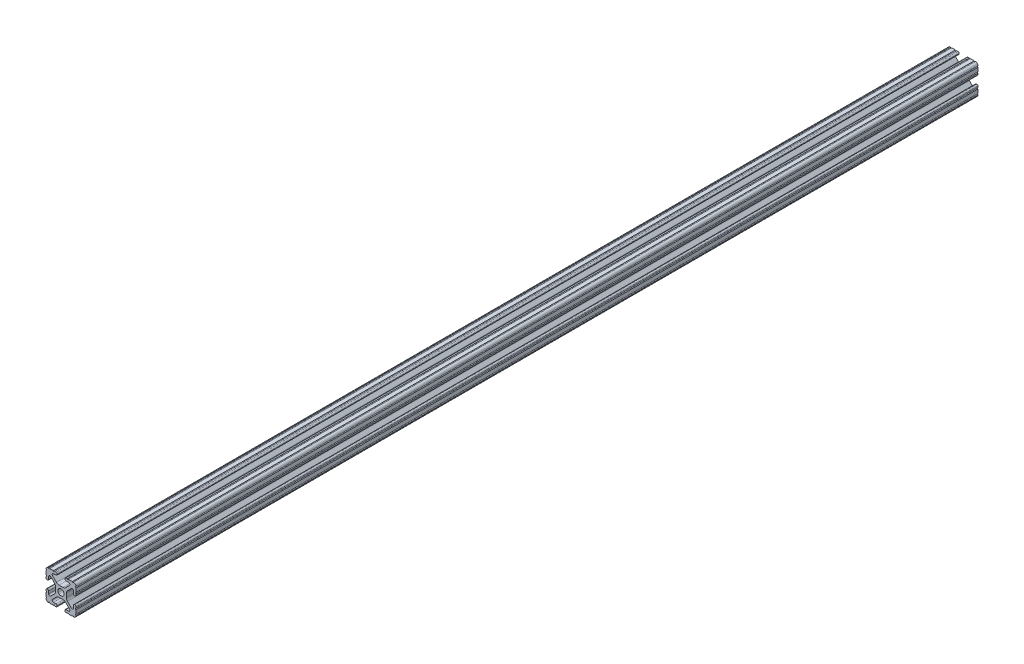
from build123d import *

# Parameters (mm, degrees)
SKETCH1_R           = 2.6035
BOSS_EXTRUDE1_DEPTH = 381


with BuildPart() as part:
    # Sketch1 → Boss-Extrude1 (new body, symmetric)
    with BuildSketch(Plane.XY):
        with BuildLine():
            Line((-7.179650497, -8.645192506), (-3.952270251, -5.423690499))
            ThreePointArc((-3.952270251, -5.423690499), (-2.922936451, -4.736929036), (-1.709253557, -4.4958))
            Line((-1.709253557, -4.4958), (1.709253557, -4.4958))
            ThreePointArc((1.709253557, -4.4958), (2.922936451, -4.736929036), (3.952270251, -5.423690499))
            Line((3.952270251, -5.423690499), (7.179650497, -8.645192506))
            ThreePointArc((7.179650497, -8.645192506), (7.41473083, -9.822813117), (6.416408329, -10.4902))
            Line((6.416408329, -10.4902), (4.287512407, -10.4902))
            ThreePointArc((4.287512407, -10.4902), (3.54574862, -10.79744862), (3.2385, -11.539212407))
            Line((3.2385, -11.539212407), (3.2385, -11.650987593))
            ThreePointArc((3.2385, -11.650987593), (3.54574862, -12.39275138), (4.287512407, -12.7))
            Line((4.287512407, -12.7), (5.317126718, -12.7))
            ThreePointArc((5.317126718, -12.7), (5.825126718, -12.192), (6.333126718, -12.7))
            Line((6.333126718, -12.7), (9.550443118, -12.7))
            ThreePointArc((9.550443118, -12.7), (10.058366869, -12.192000006), (10.566443095, -12.699847501))
            ThreePointArc((10.566443095, -12.699847501), (12.082537762, -12.08250727), (12.699846982, -10.566399977))
            ThreePointArc((12.699846982, -10.566399977), (12.192000006, -10.058323491), (12.7, -9.5504))
            Line((12.7, -9.5504), (12.7, -6.3330836))
            ThreePointArc((12.7, -6.3330836), (12.192, -5.8250836), (12.7, -5.3170836))
            Line((12.7, -5.3170836), (12.7, -4.287469289))
            ThreePointArc((12.7, -4.287469289), (12.39275138, -3.545705502), (11.650987593, -3.238456882))
            Line((11.650987593, -3.238456882), (11.539212407, -3.238456882))
            ThreePointArc((11.539212407, -3.238456882), (10.79744862, -3.545705502), (10.4902, -4.287469289))
            Line((10.4902, -4.287469289), (10.4902, -6.402089023))
            ThreePointArc((10.4902, -6.402089023), (9.856505071, -7.351067942), (8.737131347, -7.129408934))
            Line((8.737131347, -7.129408934), (5.441005833, -3.840816462))
            ThreePointArc((5.441005833, -3.840816462), (4.750877967, -2.809883091), (4.5085, -1.593185507))
            Line((4.5085, -1.593185507), (4.5085, 1.593185507))
            ThreePointArc((4.5085, 1.593185507), (4.750877967, 2.809883091), (5.441005833, 3.840816462))
            Line((5.441005833, 3.840816462), (8.737131347, 7.129408934))
            ThreePointArc((8.737131347, 7.129408934), (9.856505071, 7.351067942), (10.4902, 6.402089023))
            Line((10.4902, 6.402089023), (10.4902, 4.287469289))
            ThreePointArc((10.4902, 4.287469289), (10.79744862, 3.545705502), (11.539212407, 3.238456882))
            Line((11.539212407, 3.238456882), (11.650987593, 3.238456882))
            ThreePointArc((11.650987593, 3.238456882), (12.39275138, 3.545705502), (12.7, 4.287469289))
            Line((12.7, 4.287469289), (12.7, 5.3170836))
            ThreePointArc((12.7, 5.3170836), (12.192, 5.8250836), (12.7, 6.3330836))
            Line((12.7, 6.3330836), (12.7, 9.5504))
            ThreePointArc((12.7, 9.5504), (12.192000006, 10.058323491), (12.699846982, 10.566399977))
            ThreePointArc((12.699846982, 10.566399977), (12.082537762, 12.08250727), (10.566443095, 12.699847501))
            ThreePointArc((10.566443095, 12.699847501), (10.058366869, 12.192000006), (9.550443118, 12.7))
            Line((9.550443118, 12.7), (6.333126718, 12.7))
            ThreePointArc((6.333126718, 12.7), (5.825126718, 12.192), (5.317126718, 12.7))
            Line((5.317126718, 12.7), (4.287512407, 12.7))
            ThreePointArc((4.287512407, 12.7), (3.54574862, 12.39275138), (3.2385, 11.650987593))
            Line((3.2385, 11.650987593), (3.2385, 11.539212407))
            ThreePointArc((3.2385, 11.539212407), (3.54574862, 10.79744862), (4.287512407, 10.4902))
            Line((4.287512407, 10.4902), (6.476788598, 10.4902))
            ThreePointArc((6.476788598, 10.4902), (7.432222385, 9.85140422), (7.207036008, 8.724370562))
            Line((7.207036008, 8.724370562), (3.898272566, 5.423169045))
            ThreePointArc((3.898272566, 5.423169045), (2.869120213, 4.736787962), (1.655778399, 4.4958))
            Line((1.655778399, 4.4958), (-1.655778399, 4.4958))
            ThreePointArc((-1.655778399, 4.4958), (-2.869120213, 4.736787962), (-3.898272566, 5.423169045))
            Line((-3.898272566, 5.423169045), (-7.207036008, 8.724370562))
            ThreePointArc((-7.207036008, 8.724370562), (-7.432222385, 9.85140422), (-6.476788598, 10.4902))
            Line((-6.476788598, 10.4902), (-4.287512407, 10.4902))
            ThreePointArc((-4.287512407, 10.4902), (-3.54574862, 10.79744862), (-3.2385, 11.539212407))
            Line((-3.2385, 11.539212407), (-3.2385, 11.650987593))
            ThreePointArc((-3.2385, 11.650987593), (-3.54574862, 12.39275138), (-4.287512407, 12.7))
            Line((-4.287512407, 12.7), (-5.317126718, 12.7))
            ThreePointArc((-5.317126718, 12.7), (-5.825126718, 12.192), (-6.333126718, 12.7))
            Line((-6.333126718, 12.7), (-9.550443118, 12.7))
            ThreePointArc((-9.550443118, 12.7), (-10.058366869, 12.192000006), (-10.566443095, 12.699847501))
            ThreePointArc((-10.566443095, 12.699847501), (-12.082537762, 12.08250727), (-12.699846982, 10.566399977))
            ThreePointArc((-12.699846982, 10.566399977), (-12.192000006, 10.058323491), (-12.7, 9.5504))
            Line((-12.7, 9.5504), (-12.7, 6.3330836))
            ThreePointArc((-12.7, 6.3330836), (-12.192, 5.8250836), (-12.7, 5.3170836))
            Line((-12.7, 5.3170836), (-12.7, 4.287469289))
            ThreePointArc((-12.7, 4.287469289), (-12.39275138, 3.545705502), (-11.650987593, 3.238456882))
            Line((-11.650987593, 3.238456882), (-11.539212407, 3.238456882))
            ThreePointArc((-11.539212407, 3.238456882), (-10.79744862, 3.545705502), (-10.4902, 4.287469289))
            Line((-10.4902, 4.287469289), (-10.4902, 6.402089023))
            ThreePointArc((-10.4902, 6.402089023), (-9.856505071, 7.351067942), (-8.737131347, 7.129408934))
            Line((-8.737131347, 7.129408934), (-5.441005833, 3.840816462))
            ThreePointArc((-5.441005833, 3.840816462), (-4.750877967, 2.809883091), (-4.5085, 1.593185507))
            Line((-4.5085, 1.593185507), (-4.5085, -1.593185507))
            ThreePointArc((-4.5085, -1.593185507), (-4.750877967, -2.809883091), (-5.441005833, -3.840816462))
            Line((-5.441005833, -3.840816462), (-8.737131347, -7.129408934))
            ThreePointArc((-8.737131347, -7.129408934), (-9.856505071, -7.351067942), (-10.4902, -6.402089023))
            Line((-10.4902, -6.402089023), (-10.4902, -4.287469289))
            ThreePointArc((-10.4902, -4.287469289), (-10.79744862, -3.545705502), (-11.539212407, -3.238456882))
            Line((-11.539212407, -3.238456882), (-11.650987593, -3.238456882))
            ThreePointArc((-11.650987593, -3.238456882), (-12.39275138, -3.545705502), (-12.7, -4.287469289))
            Line((-12.7, -4.287469289), (-12.7, -5.3170836))
            ThreePointArc((-12.7, -5.3170836), (-12.192, -5.8250836), (-12.7, -6.3330836))
            Line((-12.7, -6.3330836), (-12.7, -9.5504))
            ThreePointArc((-12.7, -9.5504), (-12.192000006, -10.058323491), (-12.699846982, -10.566399977))
            ThreePointArc((-12.699846982, -10.566399977), (-12.082537762, -12.08250727), (-10.566443095, -12.699847501))
            ThreePointArc((-10.566443095, -12.699847501), (-10.058366869, -12.192000006), (-9.550443118, -12.7))
            Line((-9.550443118, -12.7), (-6.333126718, -12.7))
            ThreePointArc((-6.333126718, -12.7), (-5.825126718, -12.192), (-5.317126718, -12.7))
            Line((-5.317126718, -12.7), (-4.287512407, -12.7))
            ThreePointArc((-4.287512407, -12.7), (-3.54574862, -12.39275138), (-3.2385, -11.650987593))
            Line((-3.2385, -11.650987593), (-3.2385, -11.539212407))
            ThreePointArc((-3.2385, -11.539212407), (-3.54574862, -10.79744862), (-4.287512407, -10.4902))
            Line((-4.287512407, -10.4902), (-6.416408329, -10.4902))
            ThreePointArc((-6.416408329, -10.4902), (-7.41473083, -9.822813117), (-7.179650497, -8.645192506))
        make_face()
        Circle(SKETCH1_R, mode=Mode.SUBTRACT)
    extrude(amount=BOSS_EXTRUDE1_DEPTH, both=True)


solid = part.part
